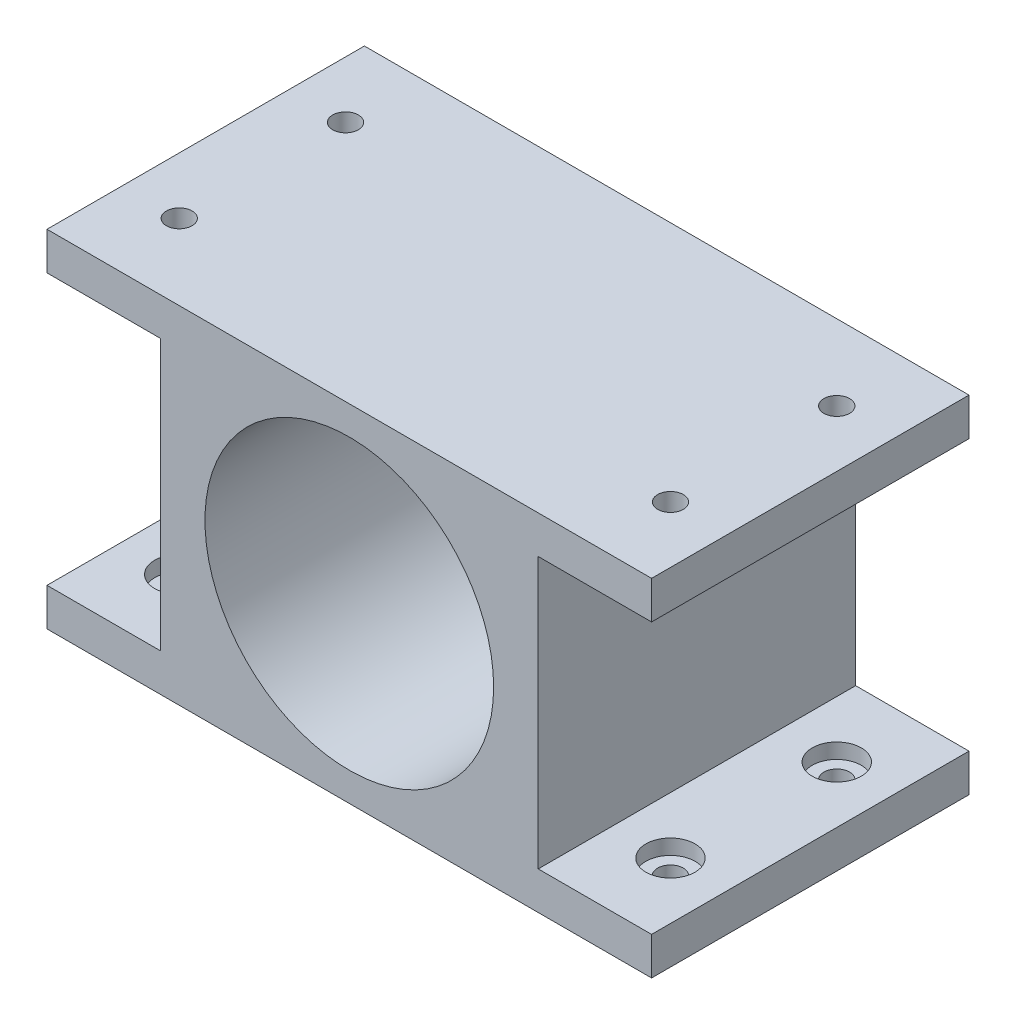
from build123d import *

# Parameters (mm, degrees)
ESQUISSE1_R                                     = 2
ESQUISSE1_R_2                                   = 11
BOSS_EXTRU_1_DEPTH                              = 2
BOSS_EXTRU_2_DEPTH                              = 40
CHAMBRAGE_POUR_VIS_T_TE_CYLINDRIQUE_D           = 3.4
CHAMBRAGE_POUR_VIS_T_TE_CYLINDRIQUE_DEPTH       = 5
CHAMBRAGE_POUR_VIS_T_TE_CYLINDRIQUE_CBORE_D     = 6.5
CHAMBRAGE_POUR_VIS_T_TE_CYLINDRIQUE_CBORE_DEPTH = 2


with BuildPart() as part:
    # Esquisse1 → Boss.-Extru.1 (new body)
    with BuildSketch(Plane.XY):
        Polygon((0, 5), (-15, 5), (-15, 0), (65, 0), (65, 5), (50, 5), (50, 40.8), (65, 40.8), (65, 45.8), (-15, 45.8), (-15, 40.8), (0, 40.8), align=None)
        with Locations((25, 38.1)):
            Circle(ESQUISSE1_R, mode=Mode.SUBTRACT)
        with Locations((11.836413862, 15.3)):
            Circle(ESQUISSE1_R, mode=Mode.SUBTRACT)
        with Locations((38.163586138, 15.3)):
            Circle(ESQUISSE1_R, mode=Mode.SUBTRACT)
        with Locations((25, 22.9)):
            Circle(ESQUISSE1_R_2, mode=Mode.SUBTRACT)
    extrude(amount=BOSS_EXTRU_1_DEPTH)

    # Esquisse3 → Boss.-Extru.2 (add)
    with BuildSketch(Plane.XY.offset(2)):
        with BuildLine():
            Line((-15, 40.8), (0, 40.8))
            Line((0, 40.8), (9.470292352, 34.019270676))
            ThreePointArc((9.470292352, 34.019270676), (25, 42), (40.529707648, 34.019270676))
            Line((40.529707648, 34.019270676), (50, 40.8))
            Line((50, 40.8), (65, 40.8))
            Line((65, 40.8), (65, 45.8))
            Line((65, 45.8), (-15, 45.8))
            Line((-15, 45.8), (-15, 40.8))
        make_face()
        with BuildLine():
            Line((9.470292352, 34.019270676), (0, 40.8))
            Line((0, 40.8), (0, 5))
            Line((0, 5), (9.470292352, 11.780729324))
            ThreePointArc((9.470292352, 11.780729324), (5.9, 22.9), (9.470292352, 34.019270676))
        make_face()
        with BuildLine():
            Line((9.470292352, 11.780729324), (0, 5))
            Line((0, 5), (-15, 5))
            Line((-15, 5), (-15, 0))
            Line((-15, 0), (65, 0))
            Line((65, 0), (65, 5))
            Line((65, 5), (50, 5))
            Line((50, 5), (40.529707648, 11.780729324))
            ThreePointArc((40.529707648, 11.780729324), (25, 3.8), (9.470292352, 11.780729324))
        make_face()
        with BuildLine():
            Line((50, 40.8), (40.529707648, 34.019270676))
            ThreePointArc((40.529707648, 34.019270676), (43.185535682, 28.739203024), (44.1, 22.9))
            ThreePointArc((44.1, 22.9), (43.185535682, 17.060796976), (40.529707648, 11.780729324))
            Line((40.529707648, 11.780729324), (50, 5))
            Line((50, 5), (50, 40.8))
        make_face()
    extrude(amount=BOSS_EXTRU_2_DEPTH)

    # Chambrage pour vis à tête cylindrique à 6 pans creux (ou vis CHC) M31
    with Locations(Plane(origin=(57.5, 5, 32), x_dir=(0, 0, 1), z_dir=(0, 1, 0))):
        with Locations((0, 0), (-22, 0), (-22, -65), (0, -65)):
            chambrage_pour_vis_t_te_cylindrique = CounterBoreHole(CHAMBRAGE_POUR_VIS_T_TE_CYLINDRIQUE_D / 2, CHAMBRAGE_POUR_VIS_T_TE_CYLINDRIQUE_CBORE_D / 2, CHAMBRAGE_POUR_VIS_T_TE_CYLINDRIQUE_CBORE_DEPTH, depth=CHAMBRAGE_POUR_VIS_T_TE_CYLINDRIQUE_DEPTH)

    # Symétrie1: Chambrage pour vis à tête cylindrique à 6 pans creux (ou vis CHC) M31 across plane
    add(chambrage_pour_vis_t_te_cylindrique.mirror(Plane.ZX.offset(22.9)), mode=Mode.SUBTRACT)


solid = part.part
